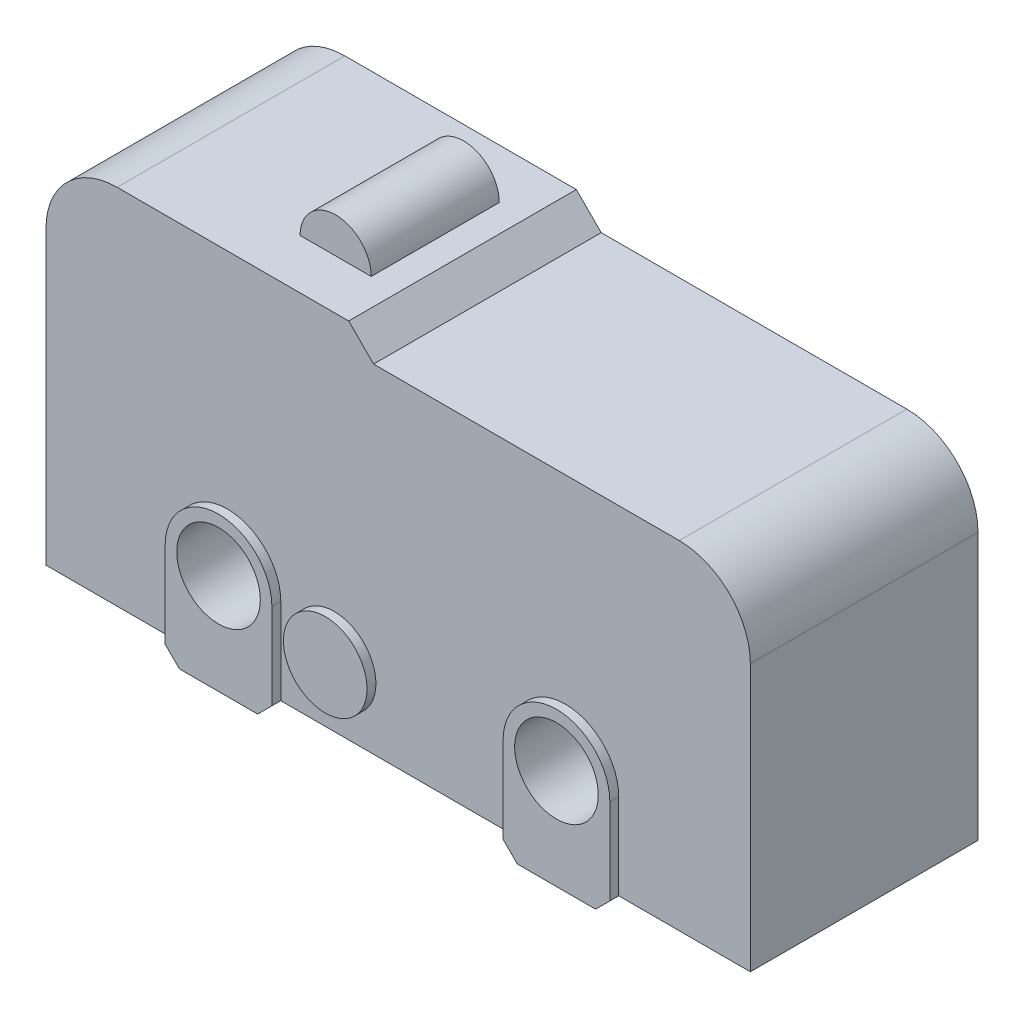
from build123d import *

# Parameters (mm, degrees)
BOSS_EXTRUDE1_DEPTH      = 6.4
SKETCH4_R                = 1.175
BOSS_EXTRUDE2_DEPTH      = 0.25
SKETCH5_R                = 1.175
BOSS_EXTRUDE3_DEPTH      = 0.25
SKETCH6_R                = 1.175
CUT_EXTRUDE1_DEPTH       = 7.9
BOSS_EXTRUDE4_DEPTH      = 1.8
BOSS_EXTRUDE4_DEPTH_BACK = 1.8


with BuildPart() as part:
    # Sketch2 → Boss-Extrude1 (new body)
    with BuildSketch(Plane.XY):
        with BuildLine():
            Line((-7.9, 10.282147184), (-1.391176502, 10.282147184))
            Line((-1.391176502, 10.282147184), (-0.691176502, 9.582147184))
            Line((-0.691176502, 9.582147184), (7.9, 9.582147184))
            ThreePointArc((7.9, 9.582147184), (9.314213562, 8.996360746), (9.9, 7.582147184))
            Line((9.9, 7.582147184), (9.9, 0.082147184))
            Line((9.9, 0.082147184), (6.2, 0.082147184))
            Line((6.2, 0.082147184), (5.8, -0.317852816))
            Line((5.8, -0.317852816), (3.6, -0.317852816))
            Line((3.6, -0.317852816), (3.2, 0.082147184))
            Line((3.2, 0.082147184), (-3.3, 0.082147184))
            Line((-3.3, 0.082147184), (-3.7, -0.317852816))
            Line((-3.7, -0.317852816), (-5.9, -0.317852816))
            Line((-5.9, -0.317852816), (-6.3, 0.082147184))
            Line((-6.3, 0.082147184), (-9.9, 0.082147184))
            Line((-9.9, 0.082147184), (-9.9, 8.282147184))
            ThreePointArc((-9.9, 8.282147184), (-9.314213562, 9.696360746), (-7.9, 10.282147184))
        make_face()
    extrude(amount=BOSS_EXTRUDE1_DEPTH)

    # Sketch4 → Boss-Extrude2 (add)
    with BuildSketch(Plane.XY.offset(6.4)):
        with Locations((-1.8, 1.832147184)):
            Circle(SKETCH4_R)
        with BuildLine():
            Line((-6.3, 2.5), (-6.3, 0.082147184))
            Line((-6.3, 0.082147184), (-5.9, -0.317852816))
            Line((-5.9, -0.317852816), (-3.7, -0.317852816))
            Line((-3.7, -0.317852816), (-3.3, 0.082147184))
            Line((-3.3, 0.082147184), (-3.3, 2.5))
            ThreePointArc((-3.3, 2.5), (-4.8, 4), (-6.3, 2.5))
        make_face()
        with BuildLine():
            Line((3.2, 2.5), (3.2, 0.082147184))
            Line((3.2, 0.082147184), (3.6, -0.317852816))
            Line((3.6, -0.317852816), (5.8, -0.317852816))
            Line((5.8, -0.317852816), (6.2, 0.082147184))
            Line((6.2, 0.082147184), (6.2, 2.5))
            ThreePointArc((6.2, 2.5), (4.7, 4), (3.2, 2.5))
        make_face()
    extrude(amount=BOSS_EXTRUDE2_DEPTH)

    # Sketch5 → Boss-Extrude3 (add)
    with BuildSketch(Plane(origin=(0, 0, 0), x_dir=(-1, 0, 0), z_dir=(0, 0, -1))):
        with Locations((1.8, 1.832147184)):
            Circle(SKETCH5_R)
        with BuildLine():
            Line((6.3, 2.5), (6.3, 0.082147184))
            Line((6.3, 0.082147184), (5.9, -0.317852816))
            Line((5.9, -0.317852816), (3.7, -0.317852816))
            Line((3.7, -0.317852816), (3.3, 0.082147184))
            Line((3.3, 0.082147184), (3.3, 2.5))
            ThreePointArc((3.3, 2.5), (4.8, 4), (6.3, 2.5))
        make_face()
        with BuildLine():
            Line((-3.2, 2.5), (-3.2, 0.082147184))
            Line((-3.2, 0.082147184), (-3.6, -0.317852816))
            Line((-3.6, -0.317852816), (-5.8, -0.317852816))
            Line((-5.8, -0.317852816), (-6.2, 0.082147184))
            Line((-6.2, 0.082147184), (-6.2, 2.5))
            ThreePointArc((-6.2, 2.5), (-4.7, 4), (-3.2, 2.5))
        make_face()
    extrude(amount=BOSS_EXTRUDE3_DEPTH)

    # Sketch6 → Cut-Extrude1 (cut, through all)
    with BuildSketch(Plane.XY.offset(6.65)):
        with Locations((-4.8, 2.5)):
            Circle(SKETCH6_R)
        with Locations((4.7, 2.5)):
            Circle(SKETCH6_R)
    extrude(amount=-CUT_EXTRUDE1_DEPTH, mode=Mode.SUBTRACT)

    # Sketch7 → Boss-Extrude4 (add, two sides)
    with BuildSketch(Plane.XY.offset(3.2)) as boss_extrude4_sk:
        with BuildLine():
            Line((-4.158024121, 10.282147184), (-2.158024121, 10.282147184))
            ThreePointArc((-2.158024121, 10.282147184), (-3.158024121, 11.282147184), (-4.158024121, 10.282147184))
        make_face()
    extrude(amount=BOSS_EXTRUDE4_DEPTH)
    extrude(boss_extrude4_sk.sketch, amount=-BOSS_EXTRUDE4_DEPTH_BACK)


solid = part.part
